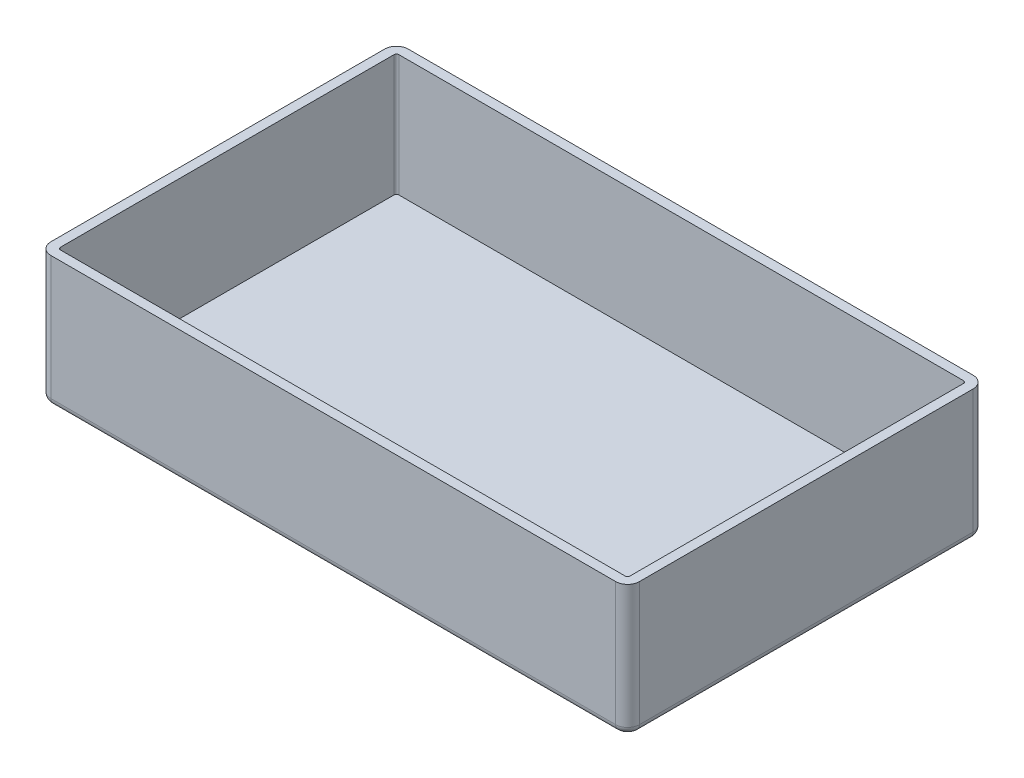
from build123d import *

# Parameters (mm, degrees)
ESBO_O1_W                = 247
ESBO_O1_H                = 150
RESSALTO_EXTRUS_O1_DEPTH = 55
FILETE1_R                = 5
FILETE2_R                = 3
CASCA1_T                 = -4


with BuildPart() as part:
    # Esboço1 → Ressalto-extrusão1 (new body)
    with BuildSketch(Plane(origin=(0, 0, 0), x_dir=(1, 0, 0), z_dir=(0, 1, 0))):
        Rectangle(ESBO_O1_W, ESBO_O1_H)
    extrude(amount=RESSALTO_EXTRUS_O1_DEPTH)

    # Filete1
    filete1_edges = [part.edges().sort_by_distance(p)[0] for p in [
        (123.5, 27.5, 75),
        (-123.5, 27.5, 75),
        (-123.5, 27.5, -75),
        (123.5, 27.5, -75),
    ]]
    fillet(filete1_edges, radius=FILETE1_R)

    # Filete2
    filete2_edges = [part.edges().sort_by_distance(p)[0] for p in [
        (-123.5, 0, 0),
        (123.5, 0, 0),
        (0, 0, 75),
        (0, 0, -75),
        (122.035533906, 0, 73.535533906),
        (122.035533906, 0, -73.535533906),
        (-122.035533906, 0, 73.535533906),
        (-122.035533906, 0, -73.535533906),
    ]]
    fillet(filete2_edges, radius=FILETE2_R)

    # Casca1
    casca1_openings = [part.faces().sort_by_distance(p)[0] for p in [
        (0, 55, 0),
    ]]
    offset(amount=CASCA1_T, openings=casca1_openings, kind=Kind.INTERSECTION)


solid = part.part
